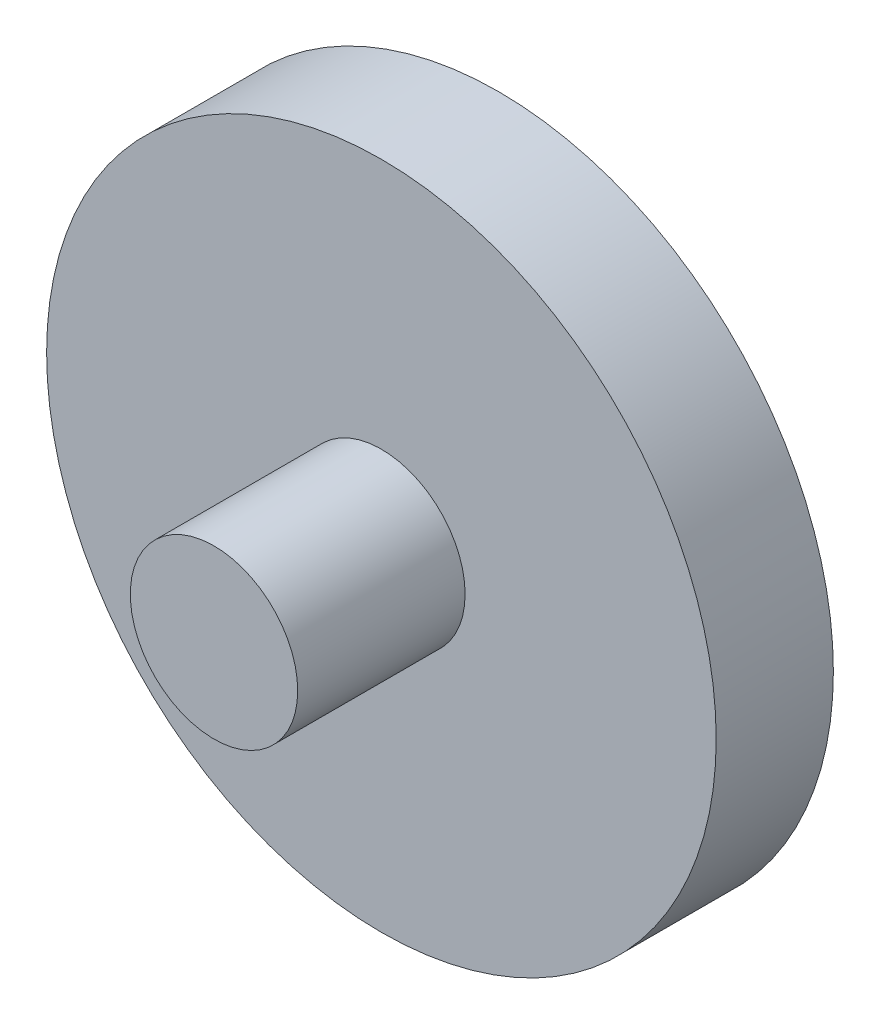
from build123d import *

# Parameters (mm, degrees)
ESQUISSE1_R        = 20
BOSS_EXTRU_1_DEPTH = 7
ESQUISSE2_R        = 5
BOSS_EXTRU_2_DEPTH = 10


with BuildPart() as part:
    # Esquisse1 → Boss.-Extru.1 (new body)
    with BuildSketch(Plane.XY):
        Circle(ESQUISSE1_R)
    extrude(amount=BOSS_EXTRU_1_DEPTH)

    # Esquisse2 → Boss.-Extru.2 (add)
    with BuildSketch(Plane.XY.offset(7)):
        Circle(ESQUISSE2_R)
    extrude(amount=BOSS_EXTRU_2_DEPTH)


solid = part.part
